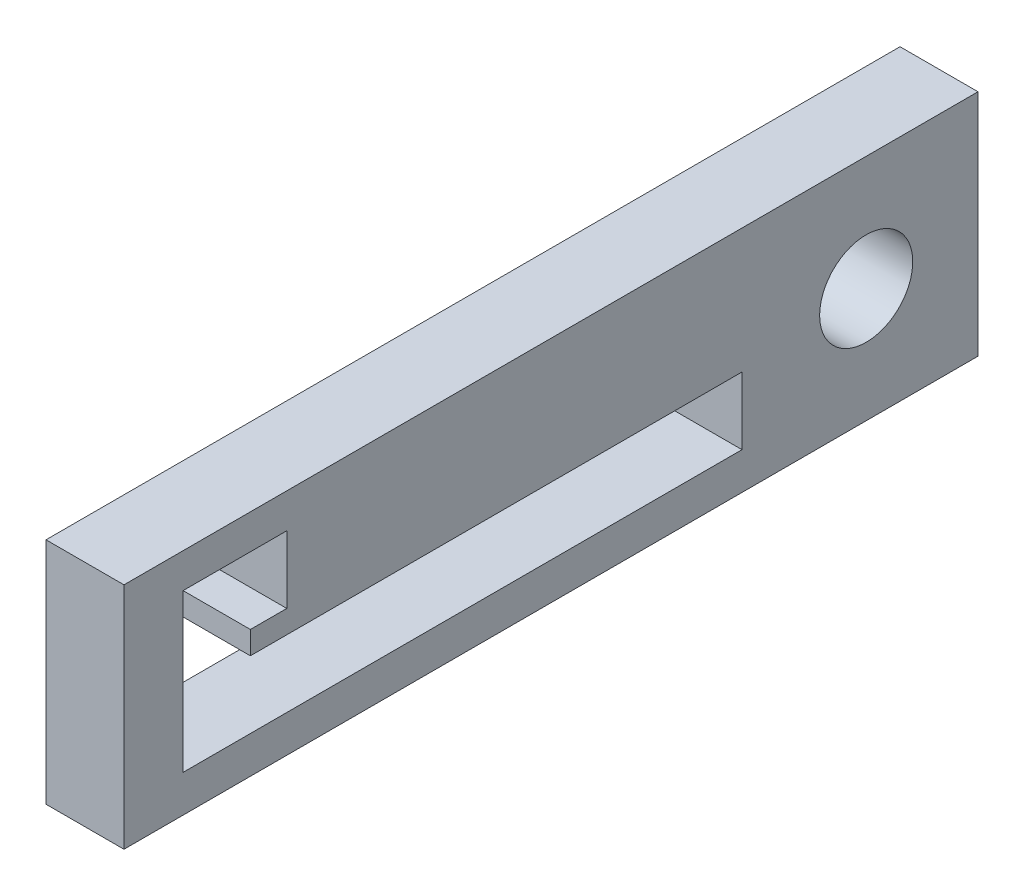
from build123d import *

# Parameters (mm, degrees)
SKETCH2_W           = 69.549132125
SKETCH2_H           = 18.652417492
SKETCH2_R           = 3.792348853
BOSS_EXTRUDE1_DEPTH = 6.35


with BuildPart() as part:
    # Sketch2 → Boss-Extrude1 (new body)
    with BuildSketch(Plane.ZY):
        with Locations((13.384474921, 36.326123608)):
            Rectangle(SKETCH2_W, SKETCH2_H)
        with Locations((-12.28496421, 36.326123608)):
            Circle(SKETCH2_R, mode=Mode.SUBTRACT)
        Polygon((-2.169792441, 30.018483291), (-2.169792441, 35.496966931), (37.864979034, 35.496966931), (37.864979034, 37.355942436), (34.900155127, 37.355942436), (34.900155127, 42.834426076), (43.343462674, 42.834426076), (43.343462674, 30.018483291), (37.864979034, 30.018483291), align=None, mode=Mode.SUBTRACT)
    extrude(amount=BOSS_EXTRUDE1_DEPTH)


solid = part.part
